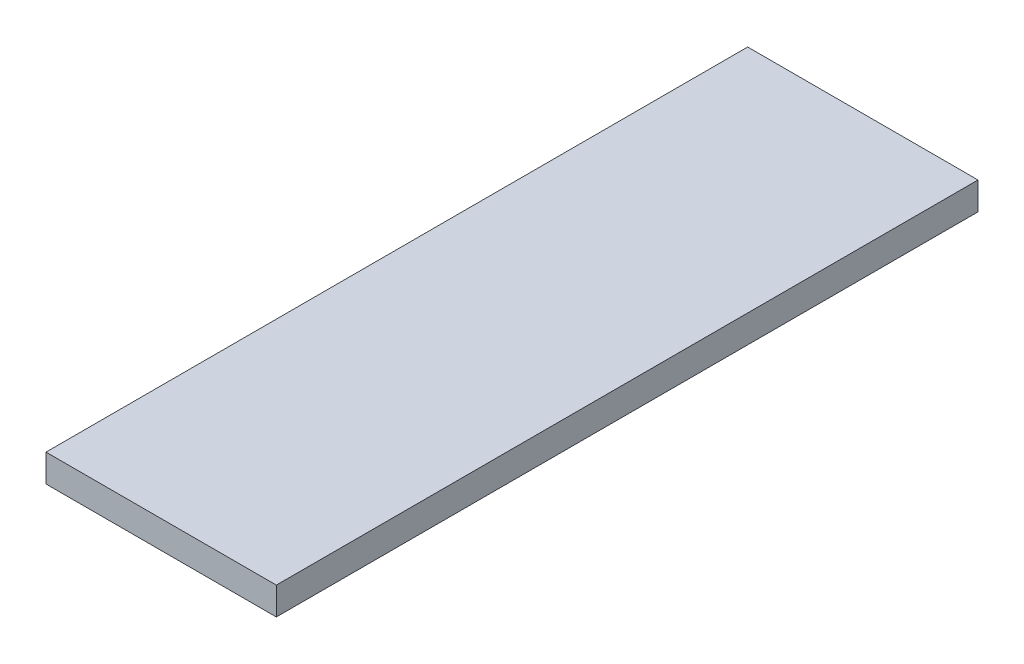
from build123d import *

# Parameters (mm, degrees)
SKETCH1_W           = 12.5
SKETCH1_H           = 38.08
BOSS_EXTRUDE1_DEPTH = 1.5


with BuildPart() as part:
    # Sketch1 → Boss-Extrude1 (new body)
    with BuildSketch(Plane(origin=(0, 0, 0), x_dir=(1, 0, 0), z_dir=(0, 1, 0))):
        Rectangle(SKETCH1_W, SKETCH1_H)
    extrude(amount=BOSS_EXTRUDE1_DEPTH)


solid = part.part
